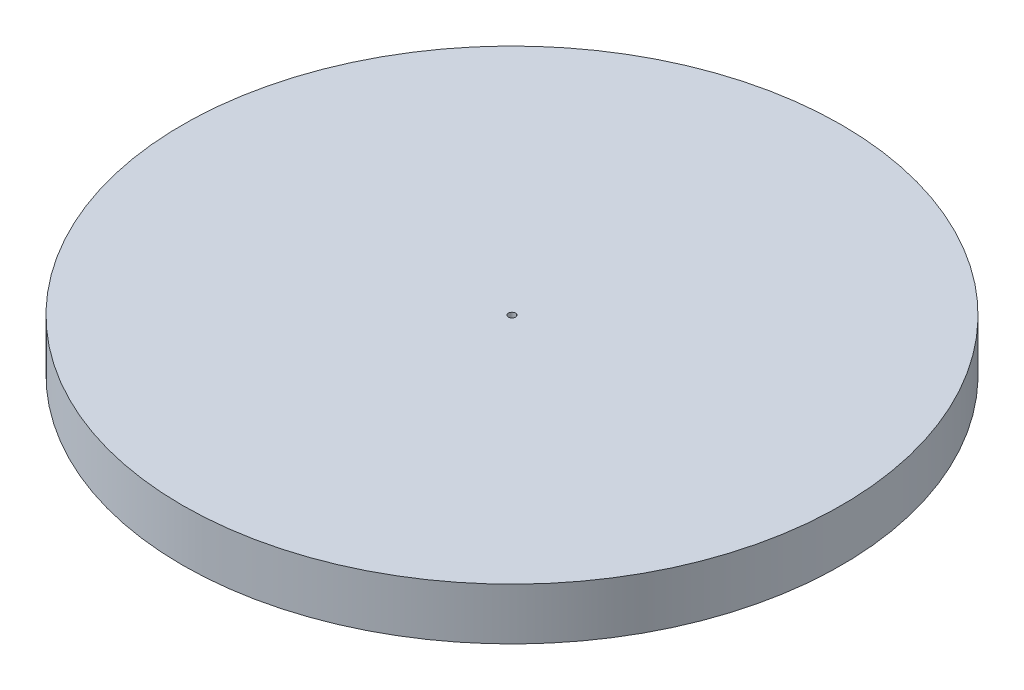
from build123d import *

# Parameters (mm, degrees)
SKETCH1_R           = 70
BOSS_EXTRUDE1_DEPTH = 11
CUT_EXTRUDE1_REACH  = 13
SKETCH3_R           = 0.75


with BuildPart() as part:
    # Sketch1 → Boss-Extrude1 (new body)
    with BuildSketch(Plane(origin=(0, 0, 0), x_dir=(1, 0, 0), z_dir=(0, 1, 0))):
        Circle(SKETCH1_R)
    extrude(amount=BOSS_EXTRUDE1_DEPTH)

    # Sketch3 → Cut-Extrude1 (cut, up to next)
    with BuildSketch(Plane(origin=(0, 11, 0), x_dir=(1, 0, 0), z_dir=(0, 1, 0)), mode=Mode.PRIVATE) as cut_extrude1_sk1:
        Circle(SKETCH3_R)
    cut_extrude1_tool1 = extrude(cut_extrude1_sk1.sketch, amount=-CUT_EXTRUDE1_REACH, mode=Mode.PRIVATE) & part.part
    add(cut_extrude1_tool1.solids().sort_by_distance((0, 11, 0))[0], mode=Mode.SUBTRACT)


solid = part.part
